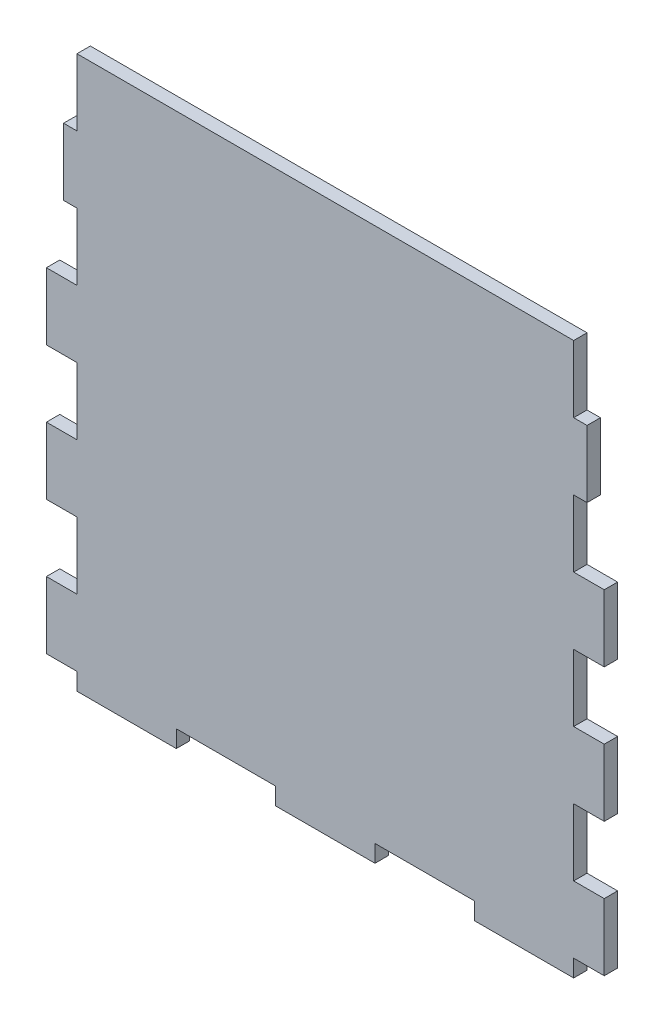
from build123d import *

# Parameters (mm, degrees)
SKETCH1_W           = 65
SKETCH1_H           = 70
BOSS_EXTRUDE1_DEPTH = 1.75
SKETCH2_W           = 4
SKETCH2_H           = 8.75
SKETCH2_W_2         = 13
SKETCH2_H_2         = 2.25
BOSS_EXTRUDE2_DEPTH = 1.75
SKETCH3_W           = 2.25
SKETCH3_H           = 8.75
CUT_EXTRUDE1_DEPTH  = 2.75


with BuildPart() as part:
    # Sketch1 → Boss-Extrude1 (new body)
    with BuildSketch(Plane.XY):
        with Locations((32.5, 35)):
            Rectangle(SKETCH1_W, SKETCH1_H)
    extrude(amount=BOSS_EXTRUDE1_DEPTH)

    # Sketch2 → Boss-Extrude2 (add)
    with BuildSketch(Plane.XY.offset(1.75)):
        with Locations((67, 39.375)):
            Rectangle(SKETCH2_W, SKETCH2_H)
        with Locations((67, 21.875)):
            Rectangle(SKETCH2_W, SKETCH2_H)
        with Locations((67, 4.375)):
            Rectangle(SKETCH2_W, SKETCH2_H)
        with Locations((6.5, -1.125)):
            Rectangle(SKETCH2_W_2, SKETCH2_H_2)
        with Locations((-2, 4.375)):
            Rectangle(SKETCH2_W, SKETCH2_H)
        with Locations((-2, 21.875)):
            Rectangle(SKETCH2_W, SKETCH2_H)
        with Locations((-2, 56.875)):
            Rectangle(SKETCH2_W, SKETCH2_H)
        with Locations((67, 56.875)):
            Rectangle(SKETCH2_W, SKETCH2_H)
        with Locations((58.5, -1.125)):
            Rectangle(SKETCH2_W_2, SKETCH2_H_2)
        with Locations((32.5, -1.125)):
            Rectangle(SKETCH2_W_2, SKETCH2_H_2)
        with Locations((-2, 39.375)):
            Rectangle(SKETCH2_W, SKETCH2_H)
    extrude(amount=-BOSS_EXTRUDE2_DEPTH)

    # Sketch3 → Cut-Extrude1 (cut, through all)
    with BuildSketch(Plane(origin=(0, 0, 0), x_dir=(-1, 0, 0), z_dir=(0, 0, -1))):
        with Locations((-67.875, 56.875)):
            Rectangle(SKETCH3_W, SKETCH3_H)
        with Locations((2.875, 56.875)):
            Rectangle(SKETCH3_W, SKETCH3_H)
    extrude(amount=-CUT_EXTRUDE1_DEPTH, mode=Mode.SUBTRACT)


solid = part.part
